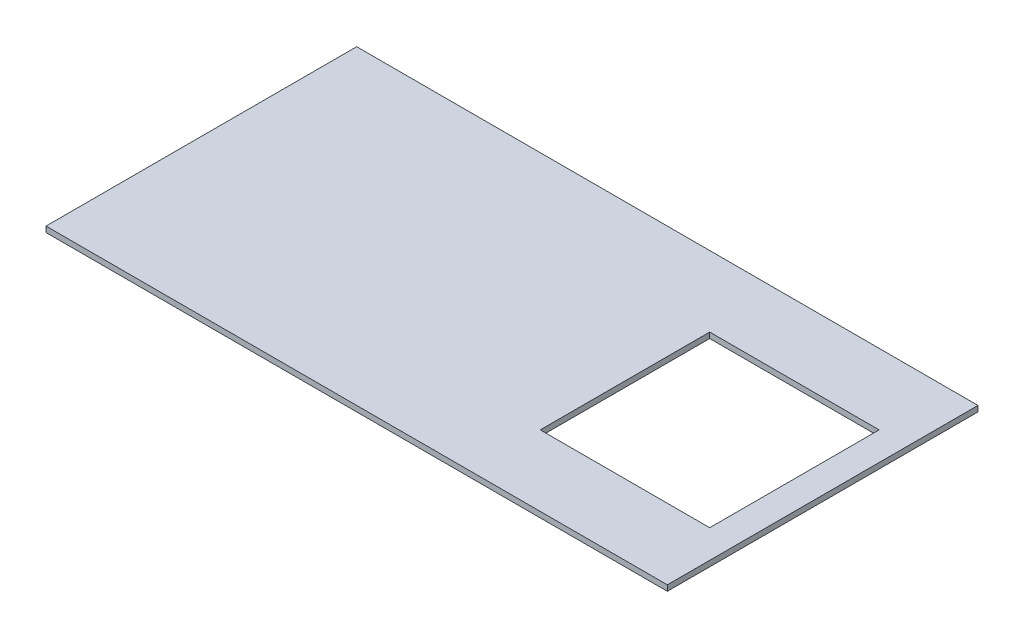
from build123d import *

# Parameters (mm, degrees)
SKETCH1_W          = 2200
SKETCH1_H          = 1100
EXTRUDE1_DEPTH     = 20
SKETCH2_W          = 600
SKETCH2_H          = 600
CUT_EXTRUDE1_DEPTH = 21


with BuildPart() as part:
    # Sketch1 → Extrude1 (new body)
    with BuildSketch(Plane(origin=(0, 0, 0), x_dir=(1, 0, 0), z_dir=(0, 1, 0))):
        with Locations((1100, 550)):
            Rectangle(SKETCH1_W, SKETCH1_H)
    extrude(amount=EXTRUDE1_DEPTH)

    # Sketch2 → Cut-Extrude1 (cut, through all)
    with BuildSketch(Plane(origin=(0, 20, 0), x_dir=(-1, 0, 0), z_dir=(0, 1, 0))):
        with Locations((-1800, -550)):
            Rectangle(SKETCH2_W, SKETCH2_H)
    extrude(amount=-CUT_EXTRUDE1_DEPTH, mode=Mode.SUBTRACT)


solid = part.part
